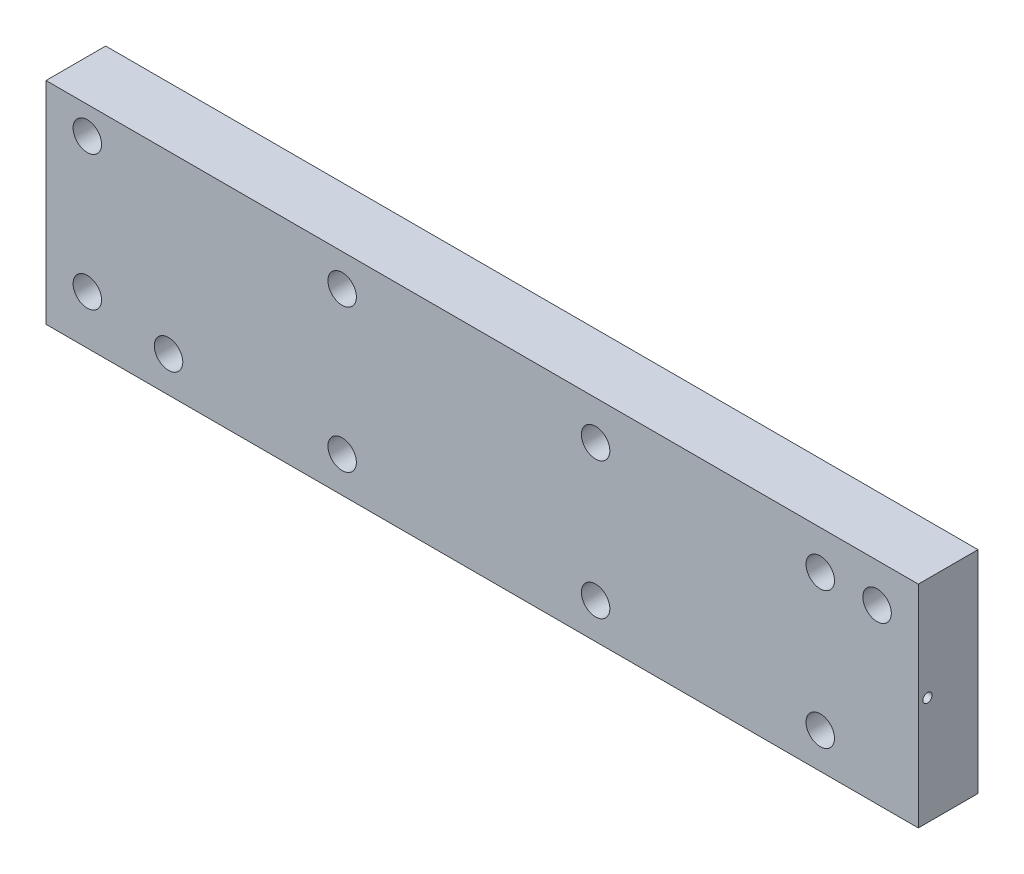
from build123d import *

# Parameters (mm, degrees)
SKIZZE2_W                                  = 120
SKIZZE2_H                                  = 40
AUFSATZ_LINEAR_AUSTRAGEN1_DEPTH            = 30
SKIZZE80_R                                 = 0.5
SCHNITT_LINEAR_AUSTRAGEN34_DEPTH           = 21.05
SCHNITT_LINEAR_START                       = -9
SKIZZE81_R                                 = 0.5
SCHNITT_LINEAR_AUSTRAGEN36_DEPTH           = 5
SKIZZE89_R                                 = 0.75
SCHNITT_LINEAR_AUSTRAGEN37_DEPTH           = 19
SKIZZE89_3_R                               = 2.1
SKIZZE89_3_R_2                             = 0.75
SCHNITT_LINEAR_AUSTRAGEN38_DEPTH           = 12
FASE1_SIZE                                 = 1.3
F_3_1_3_1_DURCHMESSER_BOHRUNG1_D           = 3.1
F_3_1_3_1_DURCHMESSER_BOHRUNG1_CSINK_D     = 3.15
F_3_1_3_1_DURCHMESSER_BOHRUNG1_CSINK_ANGLE = 90
SKIZZE83_W                                 = 8.5
SKIZZE83_H                                 = 23
SKIZZE83_W_2                               = 7
SCHNITT_LINEAR_AUSTRAGEN39_DEPTH           = 135
SKIZZE93_W                                 = 12.5
SKIZZE93_H                                 = 14.5
SCHNITT_LINEAR_AUSTRAGEN40_DEPTH           = 135
ABSPALTEN1_SURFACE_1_BACK                  = 99.814
ABSPALTEN1_SURFACE_1_DEPTH                 = 199.628


with BuildPart() as part:
    # Skizze2 → Aufsatz-Linear austragen1 (new body)
    with BuildSketch(Plane.XY):
        with Locations((60, 20)):
            Rectangle(SKIZZE2_W, SKIZZE2_H)
    extrude(amount=AUFSATZ_LINEAR_AUSTRAGEN1_DEPTH)

    # Skizze80 → Schnitt-Linear austragen34 (cut)
    with BuildSketch(Plane(origin=(120, 0, 0), x_dir=(0, 0, -1), z_dir=(1, 0, 0))):
        with Locations((-20.502569313, 19.779069372)):
            Circle(SKIZZE80_R)
    schnitt_linear_austragen34 = extrude(amount=-SCHNITT_LINEAR_AUSTRAGEN34_DEPTH, mode=Mode.SUBTRACT)

    # Skizze81 → Schnitt-Linear austragen36 (cut)
    with BuildSketch(Plane.XY.offset(30).offset(SCHNITT_LINEAR_START)):
        with Locations((99, 20)):
            Circle(SKIZZE81_R)
    schnitt_linear_austragen36 = extrude(amount=-SCHNITT_LINEAR_AUSTRAGEN36_DEPTH, mode=Mode.SUBTRACT)

    # Spiegeln4: Schnitt-Linear austragen34, Schnitt-Linear austragen36 across plane
    add(schnitt_linear_austragen34.mirror(Plane.XY.offset(15)), mode=Mode.SUBTRACT)
    add(schnitt_linear_austragen36.mirror(Plane.XY.offset(15)), mode=Mode.SUBTRACT)

    # Skizze89 → Schnitt-Linear austragen37 (cut)
    with BuildSketch(Plane.XZ):
        with Locations(Location((20.75, 10.195, 0), (0, 0, 270))):
            Circle(SKIZZE89_R)
    extrude(amount=-SCHNITT_LINEAR_AUSTRAGEN37_DEPTH, mode=Mode.SUBTRACT)

    # Skizze89_3 → Schnitt-Linear austragen38 (cut)
    with BuildSketch(Plane.XZ):
        with Locations(Location((20.75, 10.195, 0), (0, 0, 270))):
            Circle(SKIZZE89_3_R)
        with Locations(Location((20.75, 10.195, 0), (0, 0, 270))):
            Circle(SKIZZE89_3_R_2, mode=Mode.SUBTRACT)
    extrude(amount=-SCHNITT_LINEAR_AUSTRAGEN38_DEPTH, mode=Mode.SUBTRACT)

    # Fase1
    fase1_edges = [part.edges().sort_by_distance(p)[0] for p in [
        (20.75, 12, 10.945),
    ]]
    chamfer(fase1_edges, length=FASE1_SIZE)

    # 3.1 _3.1_ Durchmesser Bohrung1 (through all)
    with Locations(Plane(origin=(0, 0, 0), x_dir=(-1, 0, 0), z_dir=(0, 0, -1))):
        with Locations((-17, 28), (-44.752782077, 27.472603229), (-72.354196867, 26.76756786), (-96.819713549, 26.76756786), (-103.008357344, 26.76756786), (-17, 13.319343937), (-25.846153065, 11.883487847), (-44.752782077, 11.883487847), (-72.354196867, 11.883487847), (-96.819713549, 11.883487847)):
            CounterSinkHole(F_3_1_3_1_DURCHMESSER_BOHRUNG1_D / 2, F_3_1_3_1_DURCHMESSER_BOHRUNG1_CSINK_D / 2, counter_sink_angle=F_3_1_3_1_DURCHMESSER_BOHRUNG1_CSINK_ANGLE)

    # Skizze83 → Schnitt-Linear austragen39 (cut)
    with BuildSketch(Plane.ZY):
        with Locations((25.75, 19.5)):
            Rectangle(SKIZZE83_W, SKIZZE83_H)
        Polygon((30, 0), (30, 8), (21.5, 8), (7, 8), (0, 8), (0, 0), align=None)
        with Locations((3.5, 19.5)):
            Rectangle(SKIZZE83_W_2, SKIZZE83_H)
        Polygon((21.5, 31), (30, 31), (30, 40), (0, 40), (0, 31), (7, 31), align=None)
    extrude(amount=-SCHNITT_LINEAR_AUSTRAGEN39_DEPTH, mode=Mode.SUBTRACT)

    # Skizze93 → Schnitt-Linear austragen40 (cut)
    with BuildSketch(Plane(origin=(0, 31, 0), x_dir=(1, 0, 0), z_dir=(0, 1, 0))):
        with Locations((113.75, -14.25)):
            Rectangle(SKIZZE93_W, SKIZZE93_H)
        with Locations((6.25, -14.25)):
            Rectangle(SKIZZE93_W, SKIZZE93_H)
    extrude(amount=-SCHNITT_LINEAR_AUSTRAGEN40_DEPTH, mode=Mode.SUBTRACT)

    # Skizze99 → Schnitt-Rotation2 (revolve, cut)
    with BuildSketch(Plane.XY.offset(15), mode=Mode.PRIVATE) as schnitt_rotation2_sk:
        Polygon((14.5, 19.495348829), (14.5, 22.595348829), (20, 22.595348829), (20, 25.095348829), (100, 23.383720543), (100, 20.883720543), (105.5, 20.883720543), (105.5, 19.283720543), align=None)
    revolve(schnitt_rotation2_sk.sketch.rotate(Axis((12.5, 19.5, 15), (0.9999972958368729, -0.0023255792701378343, 0)), 180), axis=Axis((12.5, 19.5, 15), (0.9999972958368729, -0.0023255792701378343, 0)), mode=Mode.SUBTRACT)

    # Abspalten1: cut with a surface, the side behind it stays
    # Abspalten1 surface: a surface, the sketch's curves swept straight by 199.628 mm
    with BuildLine(Plane(origin=(107.5, 0, 0), x_dir=(0, 0, -1), z_dir=(1, 0, 0)).offset(-ABSPALTEN1_SURFACE_1_BACK), mode=Mode.PRIVATE) as abspalten1_surface_1_path:
        Line((-15, 31), (-15, 8))
    abspalten1_surface_1 = Shell.extrude(abspalten1_surface_1_path.wire(), (1 * ABSPALTEN1_SURFACE_1_DEPTH, 0 * ABSPALTEN1_SURFACE_1_DEPTH, 0 * ABSPALTEN1_SURFACE_1_DEPTH))
    split(bisect_by=abspalten1_surface_1, keep=Keep.BOTTOM)


solid = part.part
